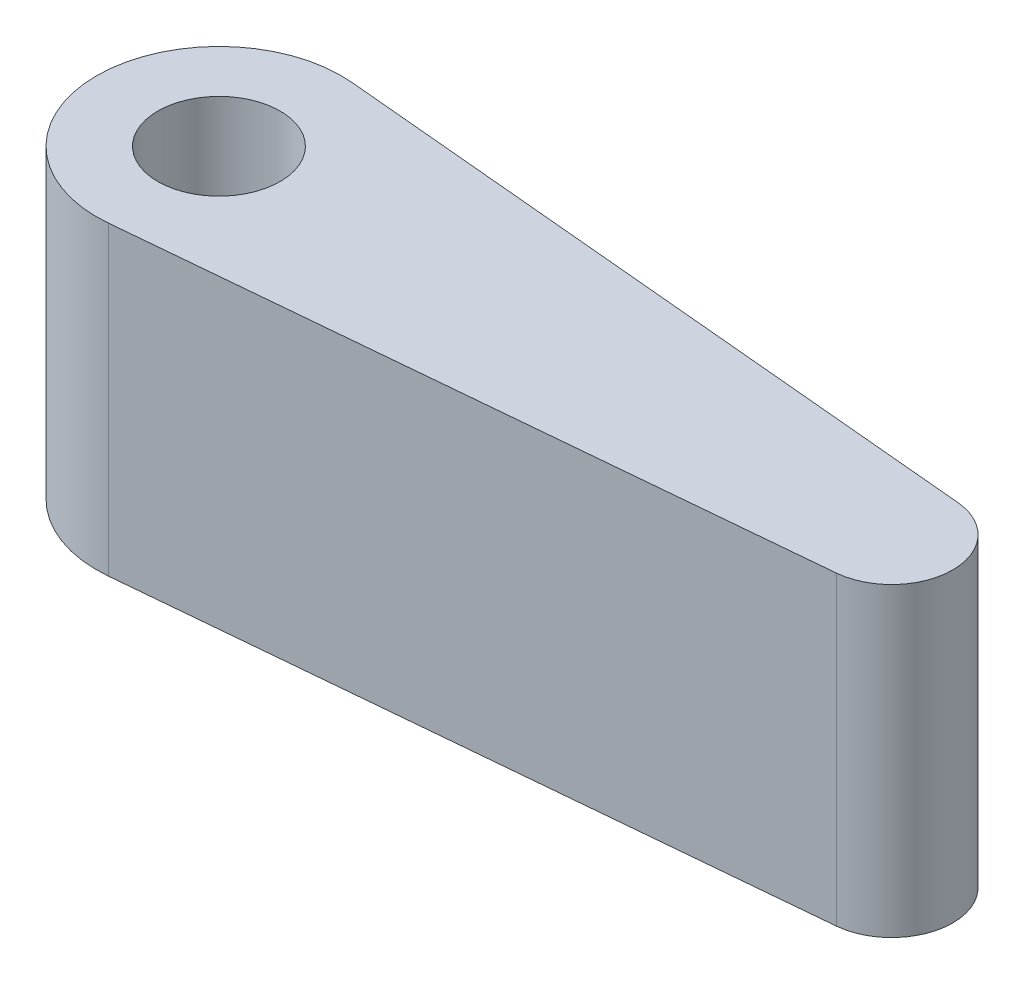
from build123d import *

# Parameters (mm, degrees)
SKETCH1_R           = 5
BOSS_EXTRUDE1_DEPTH = 25


with BuildPart() as part:
    # Sketch1 → Boss-Extrude1 (new body)
    with BuildSketch(Plane(origin=(0, 0, 0), x_dir=(1, 0, 0), z_dir=(0, 1, 0))):
        with BuildLine():
            Line((-24.090909091, 9.958591955), (30.454545455, 4.979295977))
            ThreePointArc((30.454545455, 4.979295977), (35, 0), (30.454545455, -4.979295977))
            Line((30.454545455, -4.979295977), (-24.090909091, -9.958591955))
            ThreePointArc((-24.090909091, -9.958591955), (-35, 0), (-24.090909091, 9.958591955))
        make_face()
        with Locations((-25, 0)):
            Circle(SKETCH1_R, mode=Mode.SUBTRACT)
    extrude(amount=BOSS_EXTRUDE1_DEPTH)


solid = part.part
